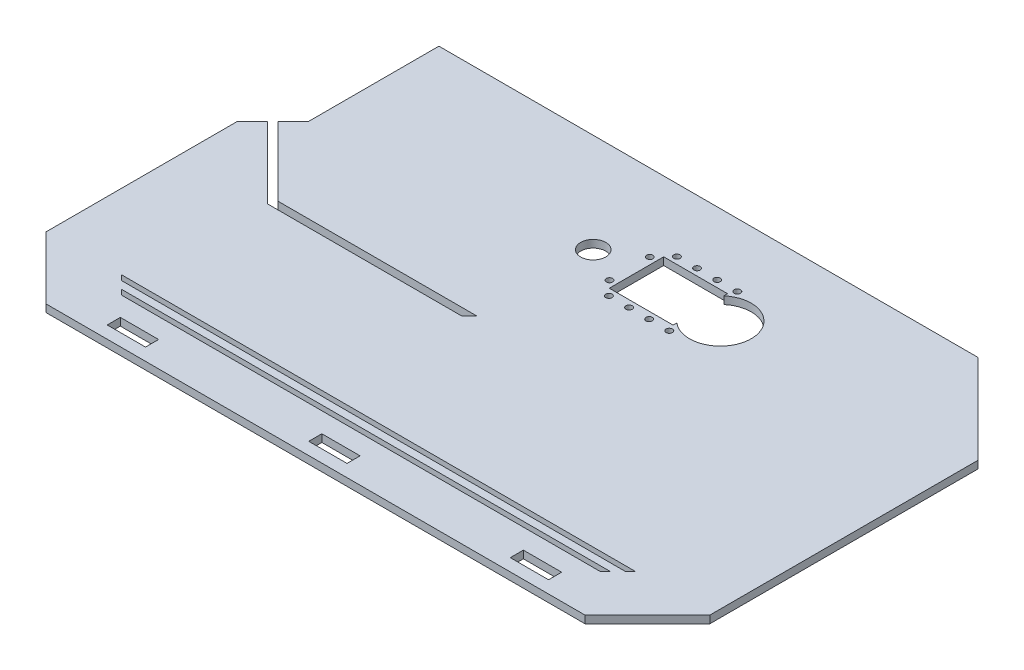
from build123d import *

# Parameters (mm, degrees)
BOSS_EXTRUDE1_DEPTH         = 3
SKETCH2_W                   = 15
SKETCH2_H                   = 5
DESTEK_BAGLANT_DEPTH        = 4
SKETCH5_R                   = 5
SKETCH5_R_2                 = 1.25
MOTOR_DEPTH                 = 4
CUT_EXTRUDE2_DEPTH          = 4
CUT_EXTRUDE3_DEPTH          = 4
BOSS_EXTRUDE2_DEPTH         = 3
SKETCH9_W                   = 15.2
SKETCH9_H                   = 5.2
DESTEK_BAGLANTI_OFSET_DEPTH = 4


with BuildPart() as part:
    # Sketch1 → Boss-Extrude1 (new body)
    with BuildSketch(Plane(origin=(0, 0, 0), x_dir=(1, 0, 0), z_dir=(0, 1, 0))):
        Polygon((-107, -50), (-131.748737342, -25.251262658), (-131.748737342, 50.617257402), (-117.606601718, 64.759393026), (-117.606601718, 116.580359723), (96.393398282, 116.580359723), (131.748737342, 81.225020664), (131.748737342, -25.251262658), (107, -50), align=None)
    extrude(amount=BOSS_EXTRUDE1_DEPTH)

    # Sketch2 → Destek Baglantı (cut, through all)
    with BuildSketch(Plane(origin=(0, 3, 0), x_dir=(1, 0, 0), z_dir=(0, 1, 0))):
        with Locations((80, -42.5)):
            Rectangle(SKETCH2_W, SKETCH2_H)
        with Locations((0, -42.5)):
            Rectangle(SKETCH2_W, SKETCH2_H)
        with Locations((-80, -42.5)):
            Rectangle(SKETCH2_W, SKETCH2_H)
    extrude(amount=-DESTEK_BAGLANT_DEPTH, mode=Mode.SUBTRACT)

    # Sketch5 → Motor (cut, through all)
    with BuildSketch(Plane.XZ):
        with Locations((-17.014102848, -77.239948703)):
            Circle(SKETCH5_R)
        with Locations((25.969420718, -91.474858406)):
            Circle(SKETCH5_R_2)
        with Locations((17.969420718, -91.474858406)):
            Circle(SKETCH5_R_2)
        with Locations((9.969420718, -91.474858406)):
            Circle(SKETCH5_R_2)
        with Locations((1.969420718, -91.474858406)):
            Circle(SKETCH5_R_2)
        with Locations((-3.280579282, -85.974858406)):
            Circle(SKETCH5_R_2)
        with Locations((-3.280579282, -69.974858406)):
            Circle(SKETCH5_R_2)
        with Locations((1.969420718, -64.474858406)):
            Circle(SKETCH5_R_2)
        with Locations((9.969420718, -64.474858406)):
            Circle(SKETCH5_R_2)
        with Locations((17.969420718, -64.474858406)):
            Circle(SKETCH5_R_2)
        with Locations((25.969420718, -64.474858406)):
            Circle(SKETCH5_R_2)
        with BuildLine():
            Line((24.769420718, -88.774858406), (-0.580579282, -88.774858406))
            Line((-0.580579282, -88.774858406), (-0.580579282, -67.174858406))
            Line((-0.580579282, -67.174858406), (24.769420718, -67.174858406))
            Line((24.769420718, -67.174858406), (24.769420718, -68.654987163))
            ThreePointArc((24.769420718, -68.654987163), (44.969420718, -77.974858406), (24.769420718, -87.29472965))
            Line((24.769420718, -87.29472965), (24.769420718, -88.774858406))
        make_face()
    extrude(amount=-MOTOR_DEPTH, mode=Mode.SUBTRACT)

    # Sketch6 → Cut-Extrude2 (cut, through all)
    with BuildSketch(Plane(origin=(0, 3, 0), x_dir=(1, 0, 0), z_dir=(0, 1, 0))):
        Polygon((-125.738329701, 56.627665042), (-97.454058454, 28.343393795), (-17.454058454, 28.343393795), (-17.454058454, 31.343393795), (-96.211417767, 31.343393795), (-123.617009358, 58.748985386), align=None)
    extrude(amount=-CUT_EXTRUDE2_DEPTH, mode=Mode.SUBTRACT)

    # Sketch7 → Cut-Extrude3 (cut, through all)
    with BuildSketch(Plane(origin=(0, 3, 0), x_dir=(1, 0, 0), z_dir=(0, 1, 0))):
        Polygon((-95, -32), (95, -32), (97, -30), (-97, -30), align=None)
        Polygon((-100, -27), (-102, -25), (102, -25), (100, -27), align=None)
    extrude(amount=-CUT_EXTRUDE3_DEPTH, mode=Mode.SUBTRACT)

    # Sketch8 → Boss-Extrude2 (add, through all)
    with BuildSketch(Plane(origin=(0, 3, 0), x_dir=(1, 0, 0), z_dir=(0, 1, 0))):
        Polygon((-17.454058454, 31.343393795), (-17.454058454, 28.343393795), (-20.454058454, 28.343393795), align=None)
    extrude(amount=-BOSS_EXTRUDE2_DEPTH)

    # Sketch9 → Destek Baglanti Ofset (cut, through all)
    with BuildSketch(Plane(origin=(0, 3, 0), x_dir=(1, 0, 0), z_dir=(0, 1, 0))):
        with Locations((-80, -42.5)):
            Rectangle(SKETCH9_W, SKETCH9_H)
        with Locations((0, -42.5)):
            Rectangle(SKETCH9_W, SKETCH9_H)
        with Locations((80, -42.5)):
            Rectangle(SKETCH9_W, SKETCH9_H)
    extrude(amount=-DESTEK_BAGLANTI_OFSET_DEPTH, mode=Mode.SUBTRACT)


solid = part.part
